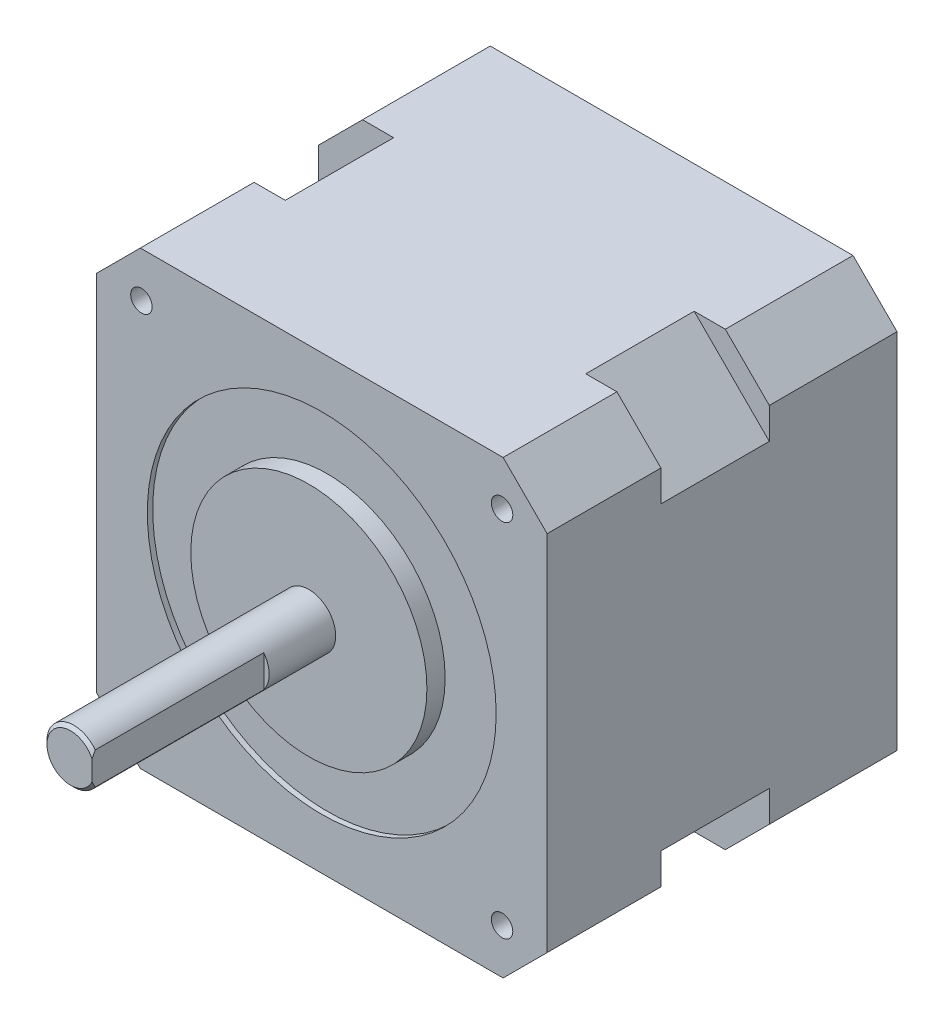
from build123d import *

# Parameters (mm, degrees)
BOSS_EXTRU_1_DEPTH      = 11.9
BOSS_EXTRU_2_DEPTH      = 10.1
BOSS_EXTRU_3_DEPTH      = 10.6
ESQUISSE4_R             = 16.25
ENL_V_MAT_EXTRU_1_DEPTH = 0.5
ESQUISSE5_R             = 11
BOSS_EXTRU_4_DEPTH      = 1.7
ESQUISSE6_R             = 2.5
BOSS_EXTRU_5_DEPTH      = 22.2
CHANFREIN1_SIZE         = 0.3
ENL_V_MAT_EXTRU_2_DEPTH = 16
ESQUISSE8_R             = 1
ENL_V_MAT_EXTRU_3_DEPTH = 7


with BuildPart() as part:
    # Esquisse1 → Boss.-Extru.1 (new body)
    with BuildSketch(Plane.XY):
        Polygon((21, -16.9), (21, 16.9), (16.9, 21), (-16.9, 21), (-21, 16.9), (-21, -16.9), (-16.9, -21), (16.9, -21), align=None)
    extrude(amount=BOSS_EXTRU_1_DEPTH)

    # Esquisse2 → Boss.-Extru.2 (add)
    with BuildSketch(Plane.XY.offset(11.9)):
        Polygon((14, 21), (21, 14), (21, -14), (14, -21), (-14, -21), (-21, -14), (-21, 14), (-14, 21), align=None)
    extrude(amount=BOSS_EXTRU_2_DEPTH)

    # Esquisse3 → Boss.-Extru.3 (add)
    with BuildSketch(Plane.XY.offset(22)):
        Polygon((16.9, 21), (21, 16.9), (21, -16.9), (16.9, -21), (-16.9, -21), (-21, -16.9), (-21, 16.9), (-16.9, 21), align=None)
    extrude(amount=BOSS_EXTRU_3_DEPTH)

    # Esquisse4 → Enlèv. mat.-Extru.1 (cut)
    with BuildSketch(Plane.XY.offset(32.6)):
        Circle(ESQUISSE4_R)
    extrude(amount=-ENL_V_MAT_EXTRU_1_DEPTH, mode=Mode.SUBTRACT)

    # Esquisse5 → Boss.-Extru.4 (add)
    with BuildSketch(Plane.XY.offset(32.1)):
        Circle(ESQUISSE5_R)
    extrude(amount=BOSS_EXTRU_4_DEPTH)

    # Esquisse6 → Boss.-Extru.5 (add)
    with BuildSketch(Plane.XY.offset(33.8)):
        Circle(ESQUISSE6_R)
    extrude(amount=BOSS_EXTRU_5_DEPTH)

    # Chanfrein1
    chanfrein1_edges = [part.edges().sort_by_distance(p)[0] for p in [
        (-2.5, 0, 56),
    ]]
    chamfer(chanfrein1_edges, length=CHANFREIN1_SIZE)

    # Esquisse7 → Enlèv. mat.-Extru.2 (cut)
    with BuildSketch(Plane.XY.offset(56)):
        with BuildLine():
            Line((2, 1.5), (2, -1.5))
            ThreePointArc((2, -1.5), (2.5, 0), (2, 1.5))
        make_face()
    extrude(amount=-ENL_V_MAT_EXTRU_2_DEPTH, mode=Mode.SUBTRACT)

    # Esquisse8 → Enlèv. mat.-Extru.3 (cut)
    with BuildSketch(Plane.XY.offset(32.6)):
        with Locations((-16.8, 16.8)):
            Circle(ESQUISSE8_R)
        with Locations((-16.8, -16.8)):
            Circle(ESQUISSE8_R)
        with Locations((16.8, -16.8)):
            Circle(ESQUISSE8_R)
        with Locations((16.8, 16.8)):
            Circle(ESQUISSE8_R)
    extrude(amount=-ENL_V_MAT_EXTRU_3_DEPTH, mode=Mode.SUBTRACT)


solid = part.part
